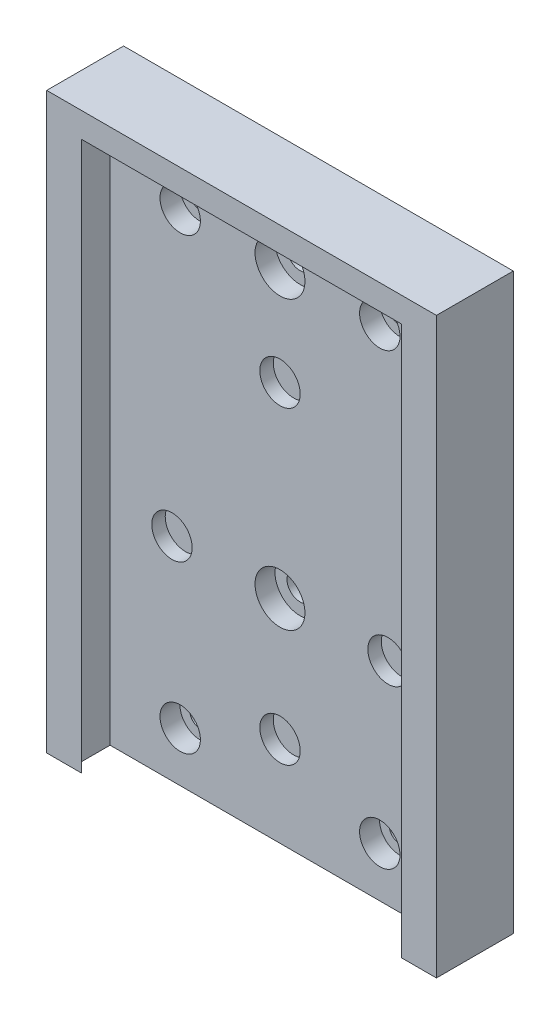
from build123d import *

# Parameters (mm, degrees)
SKETCH1_W                = 68.1
SKETCH1_H                = 110
SKETCH1_R                = 2.1
SKETCH1_R_2              = 4.05
SKETCH1_R_3              = 2.6
BOSS_EXTRUDE1_DEPTH      = 7.7
SKETCH2_R                = 6.304633146
SKETCH2_R_2              = 7.334333348
SKETCH2_R_3              = 8.114040952
SKETCH2_R_4              = 11.073656437
BOSS_EXTRUDE2_DEPTH      = 5
SKETCH3_R                = 4.05
SKETCH3_R_2              = 5
CUT_EXTRUDE1_DEPTH       = 4
SKETCH4_W                = 68.1
SKETCH4_H                = 5
BOSS_EXTRUDE3_DEPTH      = 7.7
BOSS_EXTRUDE3_DEPTH_BACK = 7.7
BOSS_EXTRUDE4_DEPTH      = 115


with BuildPart() as part:
    # Sketch1 → Boss-Extrude1 (new body)
    with BuildSketch(Plane.XY):
        Rectangle(SKETCH1_W, SKETCH1_H)
        with Locations((20, 45)):
            Circle(SKETCH1_R, mode=Mode.SUBTRACT)
        with Locations((-20, 45)):
            Circle(SKETCH1_R, mode=Mode.SUBTRACT)
        with Locations((20, -45)):
            Circle(SKETCH1_R, mode=Mode.SUBTRACT)
        with Locations((-20, -45)):
            Circle(SKETCH1_R, mode=Mode.SUBTRACT)
        with Locations((21.650635095, -12.5)):
            Circle(SKETCH1_R_2, mode=Mode.SUBTRACT)
        with Locations((0, 25)):
            Circle(SKETCH1_R_2, mode=Mode.SUBTRACT)
        with Locations((-21.650635095, -12.5)):
            Circle(SKETCH1_R_2, mode=Mode.SUBTRACT)
        with Locations((0, -36.95)):
            Circle(SKETCH1_R_2, mode=Mode.SUBTRACT)
        with Locations((0, 45)):
            Circle(SKETCH1_R_3, mode=Mode.SUBTRACT)
        with Locations((0, -12.5)):
            Circle(SKETCH1_R_3, mode=Mode.SUBTRACT)
    extrude(amount=BOSS_EXTRUDE1_DEPTH)

    # Sketch2 → Boss-Extrude2 (add)
    with BuildSketch(Plane(origin=(0, 0, 0), x_dir=(-1, 0, 0), z_dir=(0, 0, -1))):
        with Locations((-21.650635095, -12.5)):
            Circle(SKETCH2_R)
        with Locations((0, 25)):
            Circle(SKETCH2_R_2)
        with Locations((21.650635095, -12.5)):
            Circle(SKETCH2_R_3)
        with Locations((0, -36.95)):
            Circle(SKETCH2_R_4)
    extrude(amount=-BOSS_EXTRUDE2_DEPTH)

    # Sketch3 → Cut-Extrude1 (cut)
    with BuildSketch(Plane(origin=(0, 0, 7.7), x_dir=(-1, 0, 0), z_dir=(0, 0, -1))):
        with Locations((-20, 45)):
            Circle(SKETCH3_R)
        with Locations((20, 45)):
            Circle(SKETCH3_R)
        with Locations((-20, -45)):
            Circle(SKETCH3_R)
        with Locations((20, -45)):
            Circle(SKETCH3_R)
        with Locations((0, 45)):
            Circle(SKETCH3_R_2)
        with Locations((0, -12.5)):
            Circle(SKETCH3_R_2)
    extrude(amount=CUT_EXTRUDE1_DEPTH, mode=Mode.SUBTRACT)

    # Sketch4 → Boss-Extrude3 (add, two sides)
    with BuildSketch(Plane.XY.offset(7.7)) as boss_extrude3_sk:
        with Locations((0, 57.5)):
            Rectangle(SKETCH4_W, SKETCH4_H)
    extrude(amount=BOSS_EXTRUDE3_DEPTH)
    extrude(boss_extrude3_sk.sketch, amount=-BOSS_EXTRUDE3_DEPTH_BACK)

    # Sketch7 → Boss-Extrude4 (add)
    with BuildSketch(Plane.XZ.offset(55)):
        Polygon((-34.05, 15.4), (-32.05, 15.4), (-34.05, 13.4), (-34.05, 0), (-39.05, 0), (-39.05, 15.4), align=None)
        Polygon((39.05, 0), (34.05, 0), (34.05, 13.4), (32.05, 15.4), (34.05, 15.4), (39.05, 15.4), align=None)
    extrude(amount=-BOSS_EXTRUDE4_DEPTH)


solid = part.part
